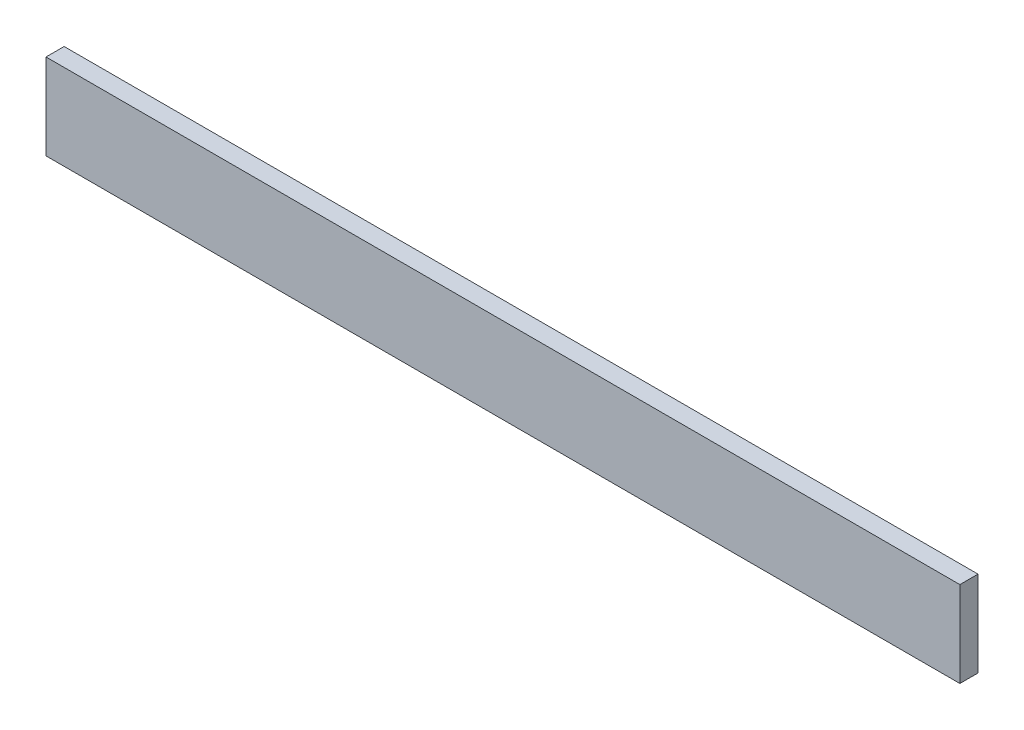
from build123d import *

# Parameters (mm, degrees)
SKETCH1_W           = 160
SKETCH1_H           = 15
BOSS_EXTRUDE1_DEPTH = 3.175


with BuildPart() as part:
    # Sketch1 → Boss-Extrude1 (new body)
    with BuildSketch(Plane.XY):
        Rectangle(SKETCH1_W, SKETCH1_H)
    extrude(amount=BOSS_EXTRUDE1_DEPTH)


solid = part.part
